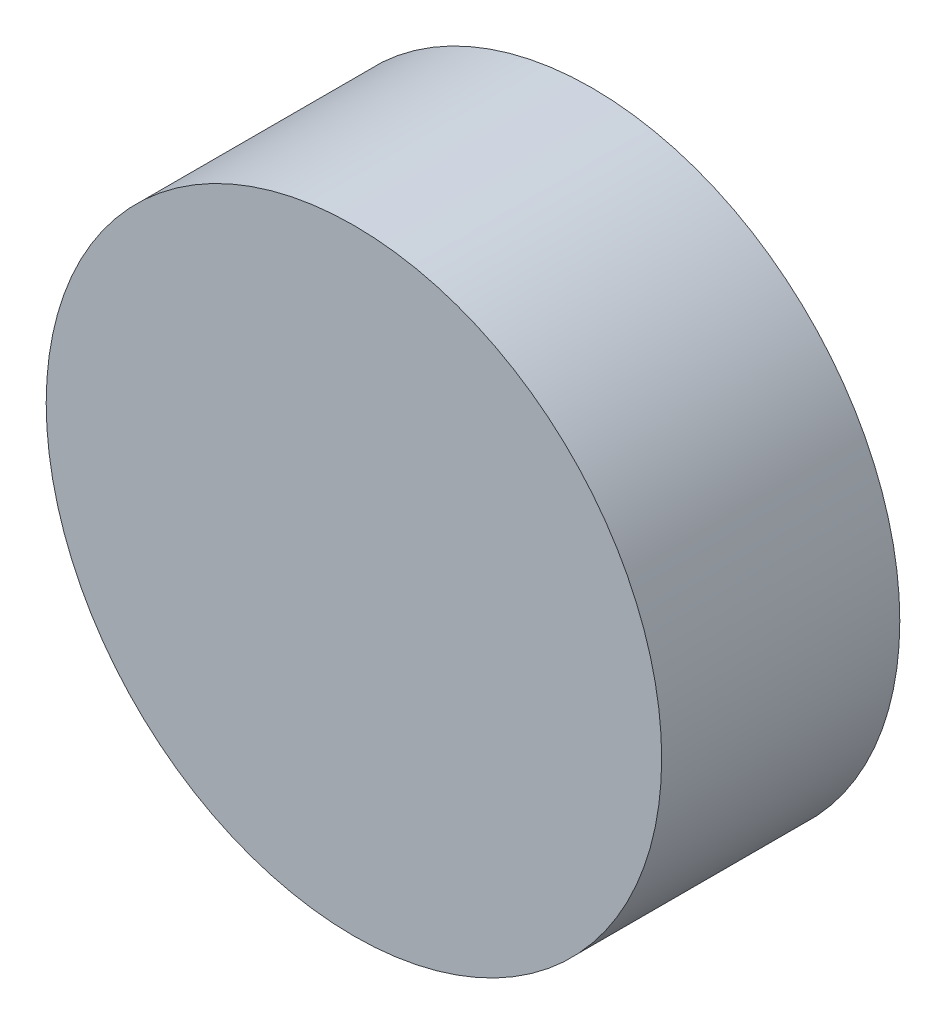
from build123d import *

# Parameters (mm, degrees)
SKETCH1_R           = 33.6
BOSS_EXTRUDE1_DEPTH = 26
SKETCH2_R           = 6.35
BOSS_EXTRUDE2_DEPTH = 4.572


with BuildPart() as part:
    # Sketch1 → Boss-Extrude1 (new body)
    with BuildSketch(Plane.XY):
        Circle(SKETCH1_R)
    extrude(amount=BOSS_EXTRUDE1_DEPTH)

    # Sketch2 → Boss-Extrude2 (add)
    with BuildSketch(Plane(origin=(0, 0, 0), x_dir=(-1, 0, 0), z_dir=(0, 0, -1))):
        Circle(SKETCH2_R)
    extrude(amount=BOSS_EXTRUDE2_DEPTH)


solid = part.part
